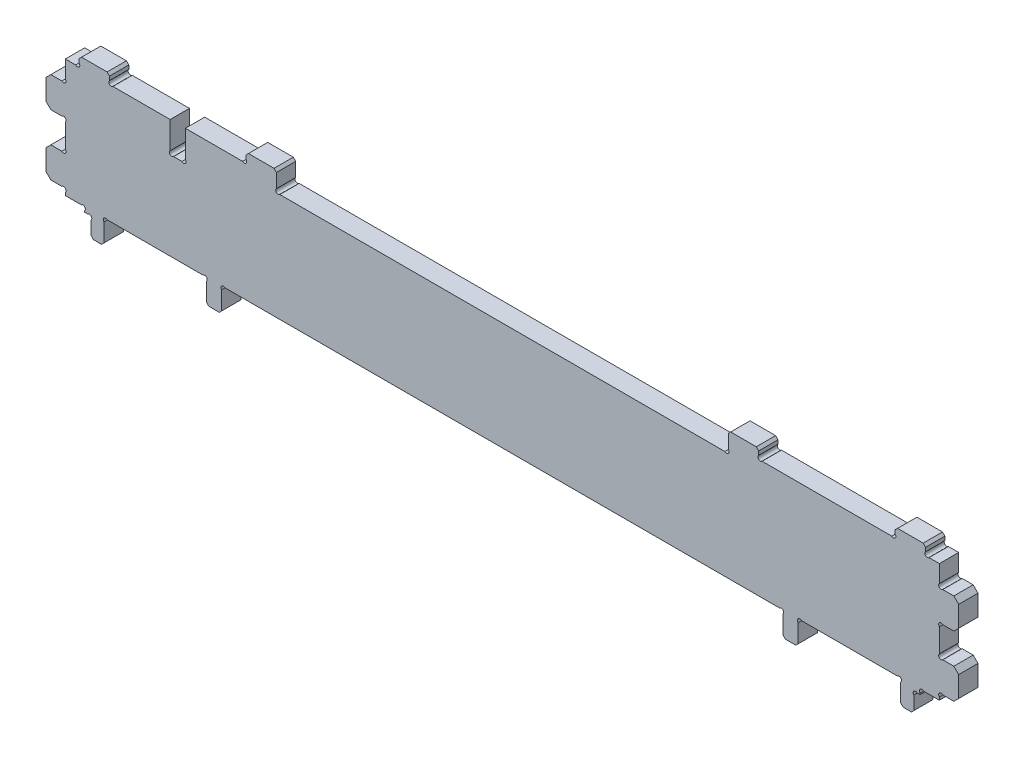
from build123d import *

# Parameters (mm, degrees)
BOSS_EXTRUDE1_DEPTH = 6.35
CHAMFER1_SIZE       = 0.79375
CHAMFER2_SIZE       = 1.5875


with BuildPart() as part:
    # Sketch1 → Boss-Extrude1 (new body)
    with BuildSketch(Plane.XY):
        with BuildLine():
            Line((134.621545702, -67.612541882), (134.621545702, -60.810273898))
            ThreePointArc((134.621545702, -60.810273898), (134.621545702, -59.687741882), (133.499013687, -59.687741882))
            Line((133.499013687, -59.687741882), (102.049077718, -59.687741882))
            ThreePointArc((102.049077718, -59.687741882), (100.926545702, -59.687741882), (100.926545702, -60.810273898))
            Line((100.926545702, -60.810273898), (100.926545702, -67.612541882))
            Line((100.926545702, -67.612541882), (95.926545702, -67.612541882))
            Line((95.926545702, -67.612541882), (95.926545702, -60.810273898))
            ThreePointArc((95.926545702, -60.810273898), (95.926545702, -59.687741882), (94.804013687, -59.687741882))
            Line((94.804013687, -59.687741882), (-87.460922281, -59.687741882))
            ThreePointArc((-87.460922281, -59.687741882), (-88.583454296, -59.687741882), (-88.583454296, -60.810273898))
            Line((-88.583454296, -60.810273898), (-88.583454296, -67.612541882))
            Line((-88.583454296, -67.612541882), (-93.583454296, -67.612541882))
            Line((-93.583454296, -67.612541882), (-93.583454296, -60.810273898))
            ThreePointArc((-93.583454296, -60.810273898), (-93.583454296, -59.687741882), (-94.705986312, -59.687741882))
            Line((-94.705986312, -59.687741882), (-126.155922281, -59.687741882))
            ThreePointArc((-126.155922281, -59.687741882), (-127.278454296, -59.687741882), (-127.278454296, -60.810273898))
            Line((-127.278454296, -60.810273898), (-127.278454296, -67.612541882))
            Line((-127.278454296, -67.612541882), (-131.507694323, -67.612541882))
            Line((-131.507694323, -67.612541882), (-131.507694323, -62.385073898))
            ThreePointArc((-131.507694323, -62.385073898), (-131.507694323, -61.262541882), (-132.630226338, -61.262541882))
            Line((-132.630226338, -61.262541882), (-133.628454296, -61.262541882))
            Line((-133.628454296, -61.262541882), (-133.628454296, -60.810273898))
            ThreePointArc((-133.628454296, -60.810273898), (-133.628454296, -59.687741882), (-134.750986312, -59.687741882))
            Line((-134.750986312, -59.687741882), (-139.978454296, -59.687741882))
            Line((-139.978454296, -59.687741882), (-139.978454296, -58.735073898))
            ThreePointArc((-139.978454296, -58.735073898), (-139.978454296, -57.612541882), (-141.100986312, -57.612541882))
            Line((-141.100986312, -57.612541882), (-146.328454296, -57.612541882))
            Line((-146.328454296, -57.612541882), (-146.328454296, -47.612541882))
            Line((-146.328454296, -47.612541882), (-141.100986312, -47.612541882))
            ThreePointArc((-141.100986312, -47.612541882), (-139.978454296, -47.612541882), (-139.978454296, -46.490009867))
            Line((-139.978454296, -46.490009867), (-139.978454296, -38.735073898))
            ThreePointArc((-139.978454296, -38.735073898), (-139.978454296, -37.612541882), (-141.100986312, -37.612541882))
            Line((-141.100986312, -37.612541882), (-146.328454296, -37.612541882))
            Line((-146.328454296, -37.612541882), (-146.328454296, -27.612541882))
            Line((-146.328454296, -27.612541882), (-141.100986312, -27.612541882))
            ThreePointArc((-141.100986312, -27.612541882), (-139.978454296, -27.612541882), (-139.978454296, -26.490009867))
            Line((-139.978454296, -26.490009867), (-139.978454296, -20.787541882))
            Line((-139.978454296, -20.787541882), (-136.575986312, -20.787541882))
            ThreePointArc((-136.575986312, -20.787541882), (-135.453454296, -20.787541882), (-135.453454296, -19.665009867))
            Line((-135.453454296, -19.665009867), (-135.453454296, -17.612541882))
            Line((-135.453454296, -17.612541882), (-125.453454296, -17.612541882))
            Line((-125.453454296, -17.612541882), (-125.453454296, -19.665009867))
            ThreePointArc((-125.453454296, -19.665009867), (-125.453454296, -20.787541882), (-124.330922281, -20.787541882))
            Line((-124.330922281, -20.787541882), (-105.521454296, -20.787541882))
            Line((-105.521454296, -20.787541882), (-105.521454296, -29.665009867))
            ThreePointArc((-105.521454296, -29.665009867), (-105.521454296, -30.787541882), (-104.398922281, -30.787541882))
            Line((-104.398922281, -30.787541882), (-101.643986312, -30.787541882))
            ThreePointArc((-101.643986312, -30.787541882), (-100.521454296, -30.787541882), (-100.521454296, -29.665009867))
            Line((-100.521454296, -29.665009867), (-100.521454296, -20.787541882))
            Line((-100.521454296, -20.787541882), (-81.711986312, -20.787541882))
            ThreePointArc((-81.711986312, -20.787541882), (-80.589454296, -20.787541882), (-80.589454296, -19.665009867))
            Line((-80.589454296, -19.665009867), (-80.589454296, -17.612541882))
            Line((-80.589454296, -17.612541882), (-70.589454296, -17.612541882))
            Line((-70.589454296, -17.612541882), (-70.589454296, -23.005209867))
            ThreePointArc((-70.589454296, -23.005209867), (-70.589454296, -24.127741882), (-69.466922281, -24.127741882))
            Line((-69.466922281, -24.127741882), (76.810013687, -24.127741882))
            ThreePointArc((76.810013687, -24.127741882), (77.932545702, -24.127741882), (77.932545702, -23.005209867))
            Line((77.932545702, -23.005209867), (77.932545702, -17.612541882))
            Line((77.932545702, -17.612541882), (87.932545702, -17.612541882))
            Line((87.932545702, -17.612541882), (87.932545702, -19.665009867))
            ThreePointArc((87.932545702, -19.665009867), (87.932545702, -20.787541882), (89.055077718, -20.787541882))
            Line((89.055077718, -20.787541882), (131.674013687, -20.787541882))
            ThreePointArc((131.674013687, -20.787541882), (132.796545702, -20.787541882), (132.796545702, -19.665009867))
            Line((132.796545702, -19.665009867), (132.796545702, -17.612541882))
            Line((132.796545702, -17.612541882), (142.796545702, -17.612541882))
            Line((142.796545702, -17.612541882), (142.796545702, -19.665009867))
            ThreePointArc((142.796545702, -19.665009867), (142.796545702, -20.787541882), (143.919077718, -20.787541882))
            Line((143.919077718, -20.787541882), (147.321545702, -20.787541882))
            Line((147.321545702, -20.787541882), (147.321545702, -26.490009867))
            ThreePointArc((147.321545702, -26.490009867), (147.321545702, -27.612541882), (148.444077718, -27.612541882))
            Line((148.444077718, -27.612541882), (153.671545702, -27.612541882))
            Line((153.671545702, -27.612541882), (153.671545702, -37.612541882))
            Line((153.671545702, -37.612541882), (148.444077718, -37.612541882))
            ThreePointArc((148.444077718, -37.612541882), (147.321545702, -37.612541882), (147.321545702, -38.735073898))
            Line((147.321545702, -38.735073898), (147.321545702, -46.490009867))
            ThreePointArc((147.321545702, -46.490009867), (147.321545702, -47.612541882), (148.444077718, -47.612541882))
            Line((148.444077718, -47.612541882), (153.671545702, -47.612541882))
            Line((153.671545702, -47.612541882), (153.671545702, -57.612541882))
            Line((153.671545702, -57.612541882), (148.444077718, -57.612541882))
            ThreePointArc((148.444077718, -57.612541882), (147.321545702, -57.612541882), (147.321545702, -58.735073898))
            Line((147.321545702, -58.735073898), (147.321545702, -59.687741882))
            Line((147.321545702, -59.687741882), (142.094077718, -59.687741882))
            ThreePointArc((142.094077718, -59.687741882), (140.971545702, -59.687741882), (140.971545702, -60.810273898))
            Line((140.971545702, -60.810273898), (140.971545702, -61.262541882))
            Line((140.971545702, -61.262541882), (140.071500685, -61.262541882))
            ThreePointArc((140.071500685, -61.262541882), (138.948968669, -61.262541882), (138.948968669, -62.385073898))
            Line((138.948968669, -62.385073898), (138.948968669, -67.612541882))
            Line((138.948968669, -67.612541882), (134.621545702, -67.612541882))
        make_face()
    extrude(amount=BOSS_EXTRUDE1_DEPTH)

    # Chamfer1
    chamfer1_edges = [part.edges().sort_by_distance(p)[0] for p in [
        (100.926545702, -67.612541882, 3.175),
        (95.926545702, -67.612541882, 3.175),
        (-88.583454296, -67.612541882, 3.175),
        (-93.583454296, -67.612541882, 3.175),
        (-127.278454296, -67.612541882, 3.175),
        (-131.507694323, -67.612541882, 3.175),
        (-135.453454296, -17.612541882, 3.175),
        (-125.453454296, -17.612541882, 3.175),
        (-80.589454296, -17.612541882, 3.175),
        (-70.589454296, -17.612541882, 3.175),
        (77.932545702, -17.612541882, 3.175),
        (87.932545702, -17.612541882, 3.175),
        (132.796545702, -17.612541882, 3.175),
        (142.796545702, -17.612541882, 3.175),
        (138.948968669, -67.612541882, 3.175),
        (134.621545702, -67.612541882, 3.175),
    ]]
    chamfer(chamfer1_edges, length=CHAMFER1_SIZE)

    # Chamfer2
    chamfer2_edges = [part.edges().sort_by_distance(p)[0] for p in [
        (-146.328454296, -57.612541882, 3.175),
        (-146.328454296, -47.612541882, 3.175),
        (-146.328454296, -37.612541882, 3.175),
        (-146.328454296, -27.612541882, 3.175),
        (153.671545702, -27.612541882, 3.175),
        (153.671545702, -37.612541882, 3.175),
        (153.671545702, -47.612541882, 3.175),
        (153.671545702, -57.612541882, 3.175),
    ]]
    chamfer(chamfer2_edges, length=CHAMFER2_SIZE)


solid = part.part
